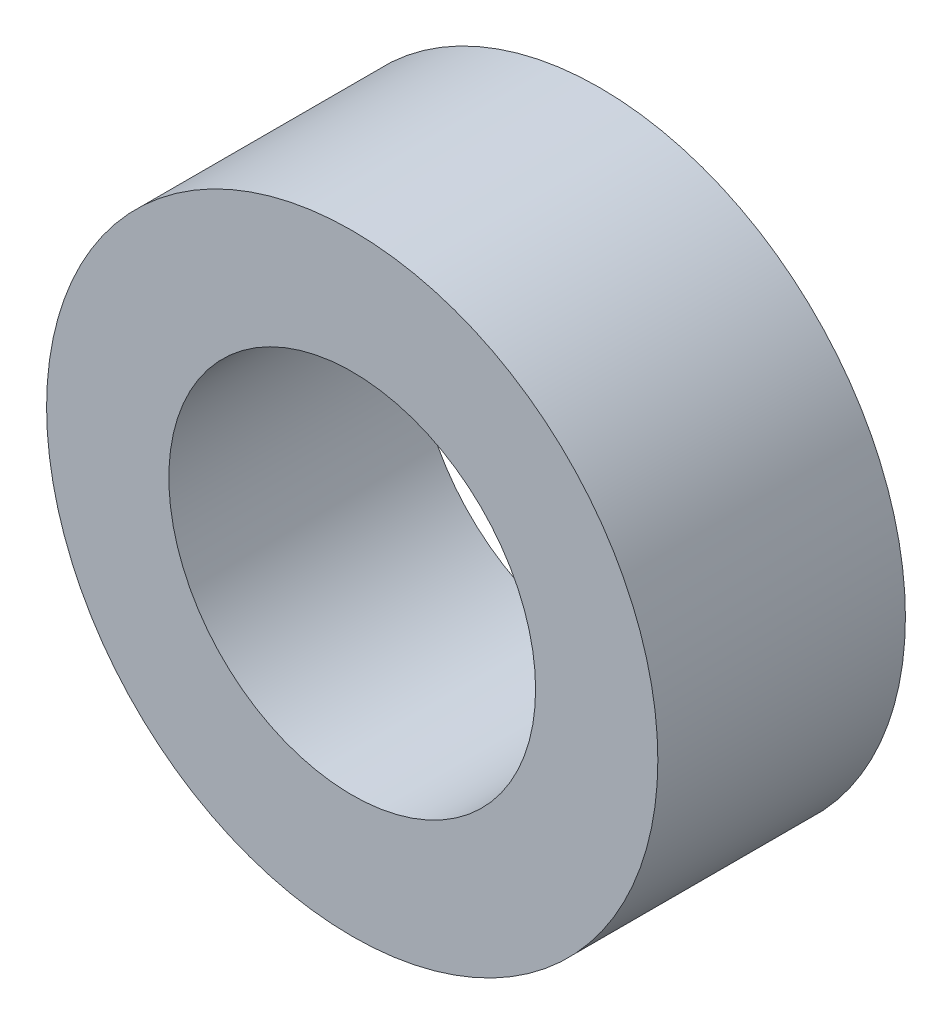
from build123d import *

# Parameters (mm, degrees)
SKETCH1_R           = 12.7
SKETCH1_R_2         = 7.62
BOSS_EXTRUDE1_DEPTH = 10.287


with BuildPart() as part:
    # Sketch1 → Boss-Extrude1 (new body)
    with BuildSketch(Plane.XY):
        Circle(SKETCH1_R)
        Circle(SKETCH1_R_2, mode=Mode.SUBTRACT)
    extrude(amount=BOSS_EXTRUDE1_DEPTH)


solid = part.part
